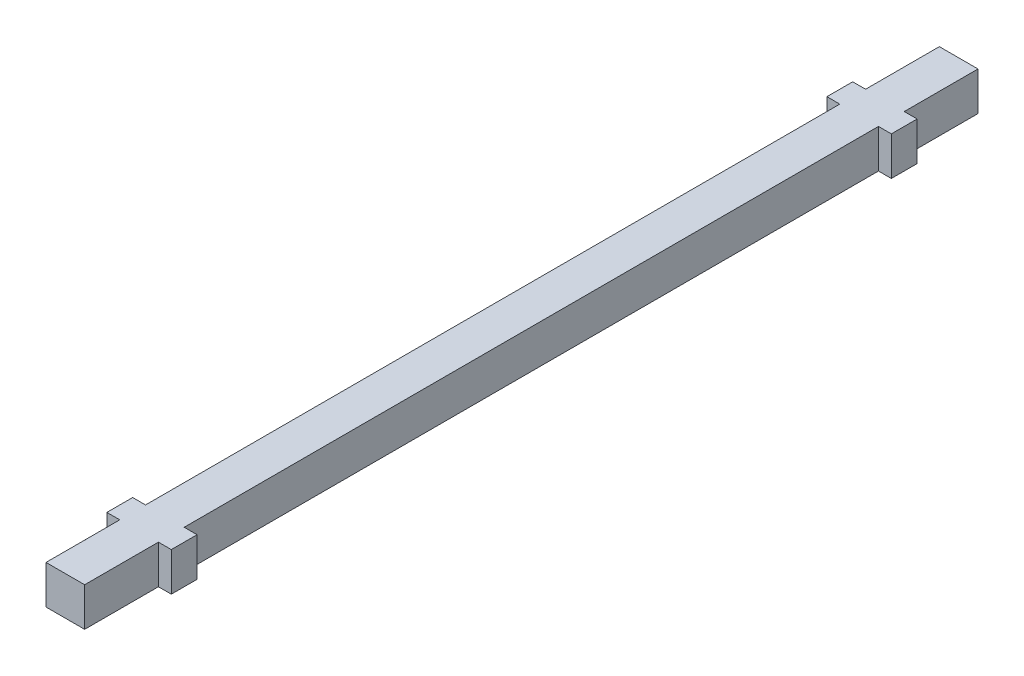
from build123d import *

# Parameters (mm, degrees)
SKETCH1_W           = 9
SKETCH1_H           = 9
BOSS_EXTRUDE1_DEPTH = 104
SKETCH2_W           = 3
SKETCH2_H           = 6
BOSS_EXTRUDE2_DEPTH = 4.5


with BuildPart() as part:
    # Sketch1 → Boss-Extrude1 (new body, symmetric)
    with BuildSketch(Plane.XY):
        Rectangle(SKETCH1_W, SKETCH1_H)
    extrude(amount=BOSS_EXTRUDE1_DEPTH, both=True)

    # Sketch2 → Boss-Extrude2 (add, symmetric)
    with BuildSketch(Plane(origin=(0, 0, 0), x_dir=(1, 0, 0), z_dir=(0, 1, 0))):
        with Locations((-6, -83.825)):
            Rectangle(SKETCH2_W, SKETCH2_H)
        with Locations((6, -83.825)):
            Rectangle(SKETCH2_W, SKETCH2_H)
        with Locations((6, 83.825)):
            Rectangle(SKETCH2_W, SKETCH2_H)
        with Locations((-6, 83.825)):
            Rectangle(SKETCH2_W, SKETCH2_H)
    extrude(amount=BOSS_EXTRUDE2_DEPTH, both=True)


solid = part.part
